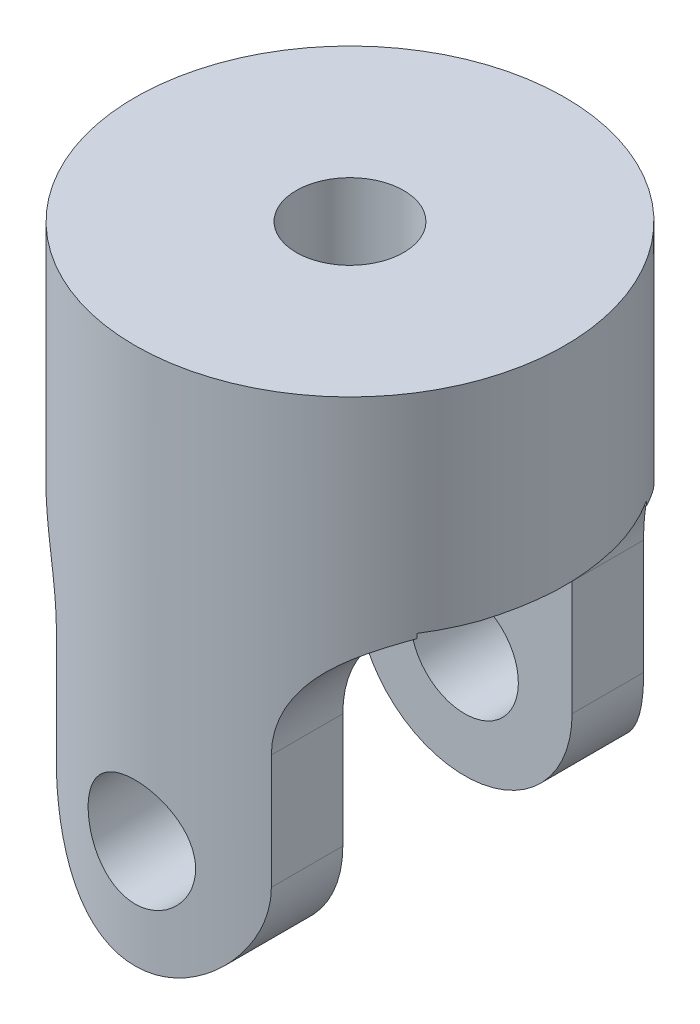
from build123d import *

# Parameters (mm, degrees)
SKETCH1_R               = 19.05
BASE_EXTRUDE_DEPTH      = 47.625
CUT_EXTRUDE1_DEPTH      = 55.716959208
CUT_EXTRUDE1_DEPTH_BACK = 55.716959208
CUT_EXTRUDE5_DEPTH      = 55.716959365
CUT_EXTRUDE5_DEPTH_BACK = 55.716959365
CUT_EXTRUDE6_DEPTH      = 55.716959365
CUT_EXTRUDE6_DEPTH_BACK = 55.716959365
SKETCH11_R              = 4.7625
SKETCH12_R              = 4.7625
CUT_EXTRUDE7_DEPTH      = 55.716959372
SCALE1_SCALE            = 0.65


with BuildPart() as part:
    # Sketch1 → Base-Extrude (new body)
    with BuildSketch(Plane(origin=(0, 0, 0), x_dir=(-1, 0, 0), z_dir=(0, 1, 0))):
        Circle(SKETCH1_R)
    extrude(amount=BASE_EXTRUDE_DEPTH)

    # Sketch2 → Cut-Extrude1 (cut, two sides: drawn at the far end of the back side and taken through both)
    with BuildSketch(Plane.XY.offset(-CUT_EXTRUDE1_DEPTH_BACK)):
        with BuildLine():
            Line((-19.05, -131.979516723), (-19.05, 0))
            Line((-19.05, 0), (-19.05, 29.21))
            ThreePointArc((-19.05, 29.21), (-12.314807909, 26.420192091), (-9.525, 19.685))
            Line((-9.525, 19.685), (-9.525, 9.525))
            ThreePointArc((-9.525, 9.525), (0, 0), (9.525, 9.525))
            Line((9.525, 9.525), (9.525, 19.685))
            ThreePointArc((9.525, 19.685), (12.314807909, 26.420192091), (19.05, 29.21))
            Line((19.05, 29.21), (19.05, 0))
            Line((19.05, 0), (19.05, -131.979516723))
            Line((19.05, -131.979516723), (19.05, -395.938550169))
            Line((19.05, -395.938550169), (-19.05, -395.938550169))
            Line((-19.05, -395.938550169), (-19.05, -131.979516723))
        make_face()
    extrude(amount=CUT_EXTRUDE1_DEPTH + CUT_EXTRUDE1_DEPTH_BACK, mode=Mode.SUBTRACT)

    # Sketch8 → Cut-Extrude5 (cut, two sides: drawn at the far end of the back side and taken through both)
    with BuildSketch(Plane(origin=(0, 0, 0), x_dir=(0, 0, -1), z_dir=(1, 0, 0)).offset(-CUT_EXTRUDE5_DEPTH_BACK)):
        Polygon((-10.16, -121.738350451), (-10.16, 0), (-10.16, 29.145238826), (10.16, 29.145238826), (10.16, 0), (10.16, -121.738350451), (10.16, -365.215051352), (-10.16, -365.215051352), align=None)
    extrude(amount=CUT_EXTRUDE5_DEPTH + CUT_EXTRUDE5_DEPTH_BACK, mode=Mode.SUBTRACT)

    # Sketch11 → Cut-Extrude6 (cut, two sides: drawn at the far end of the back side and taken through both)
    with BuildSketch(Plane.XY.offset(-CUT_EXTRUDE6_DEPTH_BACK)):
        with Locations((0, 9.525)):
            Circle(SKETCH11_R)
    extrude(amount=CUT_EXTRUDE6_DEPTH + CUT_EXTRUDE6_DEPTH_BACK, mode=Mode.SUBTRACT)

    # Sketch12 → Cut-Extrude7 (cut, through all)
    with BuildSketch(Plane(origin=(0, 47.625, 0), x_dir=(-1, 0, 0), z_dir=(0, 1, 0))):
        Circle(SKETCH12_R)
    extrude(amount=-CUT_EXTRUDE7_DEPTH, mode=Mode.SUBTRACT)


with BuildPart() as part_1:
    # Scale1: scaled about (-0.00021981, 32.483233493, 0.000100002)
    add(part.part.scale(SCALE1_SCALE).moved(Location((-7.6933e-05, 11.369131723, 3.5001e-05))))


solid = part_1.part
